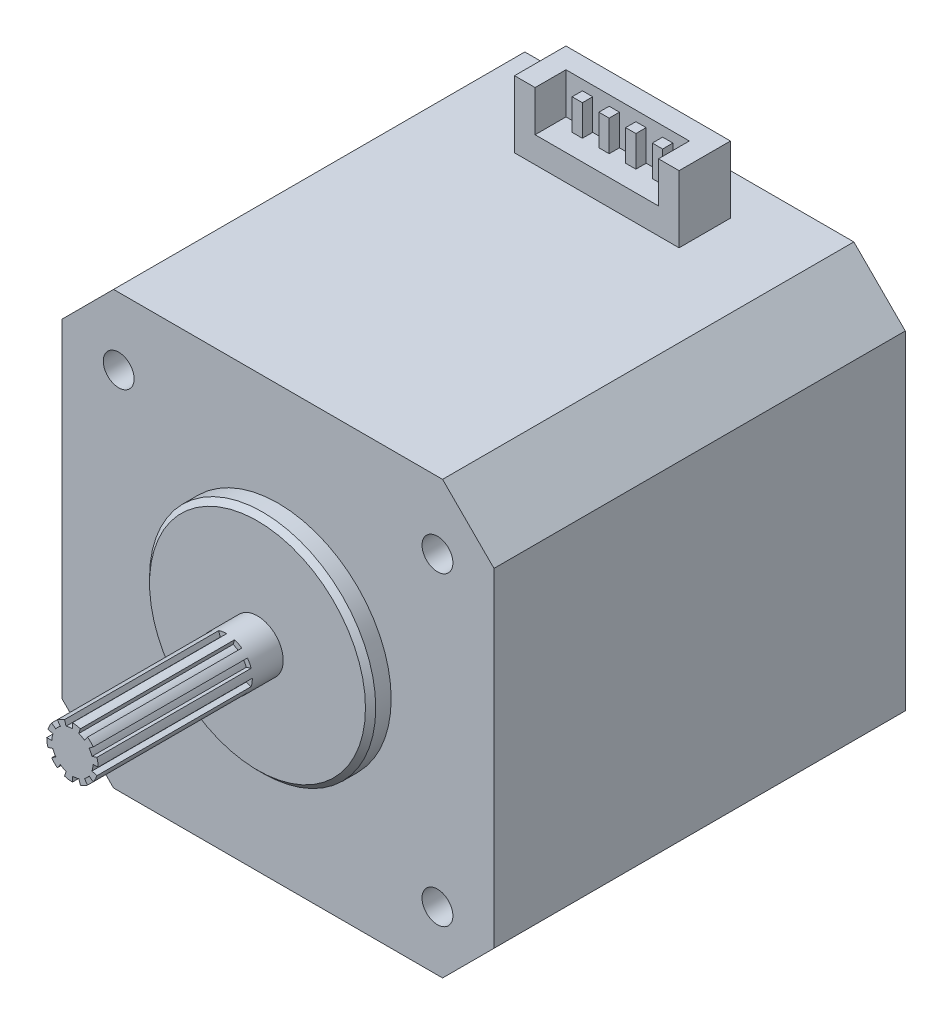
from build123d import *

# Parameters (mm, degrees)
Y_KSEKLIK_EKSTR_ZYON1_DEPTH = 40
IZIM2_R                     = 1.5
KES_EKSTR_ZYON1_DEPTH       = 40
IZIM3_R                     = 11
Y_KSEKLIK_EKSTR_ZYON2_DEPTH = 2
PAH1_SIZE                   = 0.5
IZIM4_R                     = 2.5
Y_KSEKLIK_EKSTR_ZYON3_DEPTH = 18
KES_EKSTR_ZYON2_DEPTH       = 15
IZIM6_W                     = 16
IZIM6_H                     = 5
Y_KSEKLIK_EKSTR_ZYON4_DEPTH = 6.5
IZIM7_W                     = 12
IZIM7_H                     = 3.974035492
KES_EKSTR_ZYON3_DEPTH       = 3
IZIM9_W                     = 1
IZIM9_H                     = 3
Y_KSEKLIK_EKSTR_ZYON5_DEPTH = 1


with BuildPart() as part:
    # Çizim1 → Yükseklik-Ekstrüzyon1 (new body)
    with BuildSketch(Plane.XY):
        Polygon((-21, 16), (-16, 21), (16, 21), (21, 16), (21, -16), (16, -21), (-16, -21), (-21, -16), align=None)
    extrude(amount=Y_KSEKLIK_EKSTR_ZYON1_DEPTH)

    # Çizim2 → Kes-Ekstrüzyon1 (cut)
    with BuildSketch(Plane.XY.offset(40)):
        with Locations((15.5, -15.259283602)):
            Circle(IZIM2_R)
        with Locations((-15.5, -15.259283602)):
            Circle(IZIM2_R)
        with Locations((-15.5, 14.462558328)):
            Circle(IZIM2_R)
        with Locations((15.5, 14.462558328)):
            Circle(IZIM2_R)
    extrude(amount=-KES_EKSTR_ZYON1_DEPTH, mode=Mode.SUBTRACT)

    # Çizim3 → Yükseklik-Ekstrüzyon2 (add)
    with BuildSketch(Plane.XY.offset(40)):
        Circle(IZIM3_R)
    extrude(amount=Y_KSEKLIK_EKSTR_ZYON2_DEPTH)

    # Pah1
    pah1_edges = [part.edges().sort_by_distance(p)[0] for p in [
        (-11, 0, 42),
    ]]
    chamfer(pah1_edges, length=PAH1_SIZE)

    # Çizim4 → Yükseklik-Ekstrüzyon3 (add)
    with BuildSketch(Plane.XY.offset(42)):
        Circle(IZIM4_R)
    extrude(amount=Y_KSEKLIK_EKSTR_ZYON3_DEPTH)

    # Çizim5 → Kes-Ekstrüzyon2 (cut)
    with BuildSketch(Plane.XY.offset(60)):
        with BuildLine():
            Line((2.5, 0), (2, 0))
            ThreePointArc((2, 0), (1.975376681, -0.31286893), (1.902113033, -0.618033989))
            Line((1.902113033, -0.618033989), (2.377641291, -0.772542486))
            ThreePointArc((2.377641291, -0.772542486), (2.469220851, -0.391086163), (2.5, 0))
        make_face()
        with BuildLine():
            Line((2.022542486, -1.469463131), (1.618033989, -1.175570505))
            ThreePointArc((1.618033989, -1.175570505), (1.414213562, -1.414213562), (1.175570505, -1.618033989))
            Line((1.175570505, -1.618033989), (1.469463131, -2.022542486))
            ThreePointArc((1.469463131, -2.022542486), (1.767766953, -1.767766953), (2.022542486, -1.469463131))
        make_face()
        with BuildLine():
            Line((0.772542486, -2.377641291), (0.618033989, -1.902113033))
            ThreePointArc((0.618033989, -1.902113033), (0.31286893, -1.975376681), (0, -2))
            Line((0, -2), (0, -2.5))
            ThreePointArc((0, -2.5), (0.391086163, -2.469220851), (0.772542486, -2.377641291))
        make_face()
        with BuildLine():
            Line((-0.772542486, -2.377641291), (-0.618033989, -1.902113033))
            ThreePointArc((-0.618033989, -1.902113033), (-0.907980999, -1.782013048), (-1.175570505, -1.618033989))
            Line((-1.175570505, -1.618033989), (-1.469463131, -2.022542486))
            ThreePointArc((-1.469463131, -2.022542486), (-1.134976249, -2.22751631), (-0.772542486, -2.377641291))
        make_face()
        with BuildLine():
            Line((-2.022542486, -1.469463131), (-1.618033989, -1.175570505))
            ThreePointArc((-1.618033989, -1.175570505), (-1.782013048, -0.907980999), (-1.902113033, -0.618033989))
            Line((-1.902113033, -0.618033989), (-2.377641291, -0.772542486))
            ThreePointArc((-2.377641291, -0.772542486), (-2.22751631, -1.134976249), (-2.022542486, -1.469463131))
        make_face()
        with BuildLine():
            Line((-2.5, 0), (-2, 0))
            ThreePointArc((-2, 0), (-1.975376681, 0.31286893), (-1.902113033, 0.618033989))
            Line((-1.902113033, 0.618033989), (-2.377641291, 0.772542486))
            ThreePointArc((-2.377641291, 0.772542486), (-2.469220851, 0.391086163), (-2.5, 0))
        make_face()
        with BuildLine():
            Line((-2.022542486, 1.469463131), (-1.618033989, 1.175570505))
            ThreePointArc((-1.618033989, 1.175570505), (-1.414213562, 1.414213562), (-1.175570505, 1.618033989))
            Line((-1.175570505, 1.618033989), (-1.469463131, 2.022542486))
            ThreePointArc((-1.469463131, 2.022542486), (-1.767766953, 1.767766953), (-2.022542486, 1.469463131))
        make_face()
        with BuildLine():
            Line((-0.772542486, 2.377641291), (-0.618033989, 1.902113033))
            ThreePointArc((-0.618033989, 1.902113033), (-0.31286893, 1.975376681), (0, 2))
            Line((0, 2), (0, 2.5))
            ThreePointArc((0, 2.5), (-0.391086163, 2.469220851), (-0.772542486, 2.377641291))
        make_face()
        with BuildLine():
            Line((0.772542486, 2.377641291), (0.618033989, 1.902113033))
            ThreePointArc((0.618033989, 1.902113033), (0.907980999, 1.782013048), (1.175570505, 1.618033989))
            Line((1.175570505, 1.618033989), (1.469463131, 2.022542486))
            ThreePointArc((1.469463131, 2.022542486), (1.134976249, 2.22751631), (0.772542486, 2.377641291))
        make_face()
        with BuildLine():
            Line((2.022542486, 1.469463131), (1.618033989, 1.175570505))
            ThreePointArc((1.618033989, 1.175570505), (1.782013048, 0.907980999), (1.902113033, 0.618033989))
            Line((1.902113033, 0.618033989), (2.377641291, 0.772542486))
            ThreePointArc((2.377641291, 0.772542486), (2.22751631, 1.134976249), (2.022542486, 1.469463131))
        make_face()
    extrude(amount=-KES_EKSTR_ZYON2_DEPTH, mode=Mode.SUBTRACT)

    # Çizim6 → Yükseklik-Ekstrüzyon4 (add)
    with BuildSketch(Plane(origin=(0, 21, 0), x_dir=(1, 0, 0), z_dir=(0, 1, 0))):
        with Locations((0, -6.5)):
            Rectangle(IZIM6_W, IZIM6_H)
    extrude(amount=Y_KSEKLIK_EKSTR_ZYON4_DEPTH)

    # Çizim7 → Kes-Ekstrüzyon3 (cut)
    with BuildSketch(Plane.XY.offset(9)):
        with Locations((0, 25.512982254)):
            Rectangle(IZIM7_W, IZIM7_H)
    extrude(amount=-KES_EKSTR_ZYON3_DEPTH, mode=Mode.SUBTRACT)

    # Çizim9 → Yükseklik-Ekstrüzyon5 (add)
    with BuildSketch(Plane.XY.offset(6)):
        with Locations((3.9, 25.025964508)):
            Rectangle(IZIM9_W, IZIM9_H)
        with Locations((1.3, 25.025964508)):
            Rectangle(IZIM9_W, IZIM9_H)
        with Locations((-1.3, 25.025964508)):
            Rectangle(IZIM9_W, IZIM9_H)
        with Locations((-3.9, 25.025964508)):
            Rectangle(IZIM9_W, IZIM9_H)
    extrude(amount=Y_KSEKLIK_EKSTR_ZYON5_DEPTH)


solid = part.part
